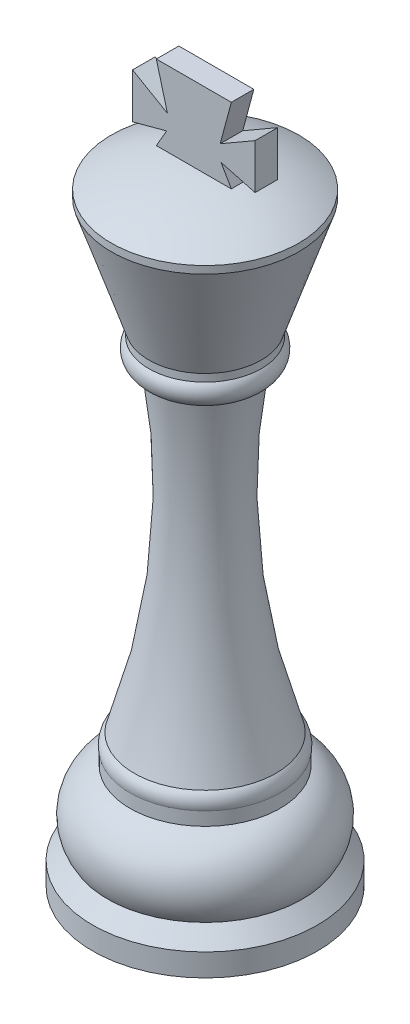
from build123d import *

# Parameters (mm, degrees)
BOSS_EXTRUDE1_DEPTH = 1.5


with BuildPart() as part:
    # Sketch2 → Revolve2 (revolve)
    with BuildSketch(Plane.XY):
        with BuildLine():
            Line((0, 0), (-15, 0))
            Line((-15, 0), (-15, 3))
            Line((-15, 3), (-13, 5))
            ThreePointArc((-13, 5), (-13.688325627, 10.216881481), (-10, 13.97))
            Line((-10, 13.97), (-10, 15.75))
            ThreePointArc((-10, 15.75), (-10.004542035, 16.82687406), (-9.45, 17.75))
            ThreePointArc((-9.45, 17.75), (-5.180228784, 38.758083651), (-6, 60.18))
            ThreePointArc((-6, 60.18), (-7.820078528, 61.356530786), (-7.5, 63.5))
            Line((-7.5, 63.5), (-7.5, 64.5))
            Line((-7.5, 64.5), (-12.5, 79.5))
            Line((-12.5, 79.5), (-12.5, 80.5))
            ThreePointArc((-12.5, 80.5), (-6.464902058, 82.956491046), (0, 83.77))
            Line((0, 83.77), (0, 0))
        make_face()
    revolve(axis=Axis((0, -79.69301575, 0), (0, 1, 0)))


with BuildPart() as body_2:
    # Sketch3 → Boss-Extrude1 (new body, symmetric)
    with BuildSketch(Plane.XY):
        Polygon((5, 93.77), (-5, 93.77), (-3.519138795, 88.243350745), (-8.171354159, 90.929308538), (-8.171354159, 84.929308538), (-3.628074115, 86.146676757), (-4.999999981, 83.770431453), (0, 83.77), (4.999999981, 83.770431453), (3.628074115, 86.146676757), (8.171354159, 84.929308538), (8.171354159, 90.929308538), (3.519138795, 88.243350745), align=None)
    extrude(amount=BOSS_EXTRUDE1_DEPTH, both=True)


solid = Compound([part.part, body_2.part])
